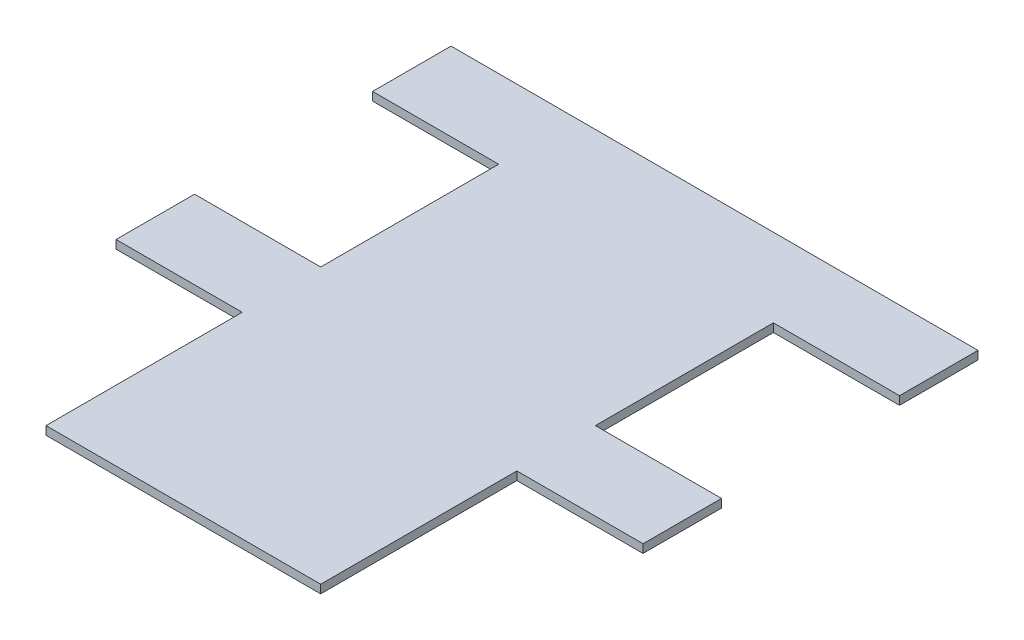
from build123d import *

# Parameters (mm, degrees)
BOSS_EXTRUDE1_DEPTH = 1.5


with BuildPart() as part:
    # Sketch2 → Boss-Extrude1 (new body)
    with BuildSketch(Plane(origin=(0, 0, 0), x_dir=(1, 0, 0), z_dir=(0, 1, 0))):
        Polygon((-22.5, 94.75), (-22.5, 80.75), (0, 80.75), (0, 49), (-22.5, 49), (-22.5, 35), (0, 35), (0, 0), (49, 0), (49, 35), (71.5, 35), (71.5, 49), (49, 49), (49, 80.75), (71.5, 80.75), (71.5, 94.75), align=None)
    extrude(amount=BOSS_EXTRUDE1_DEPTH)


solid = part.part
